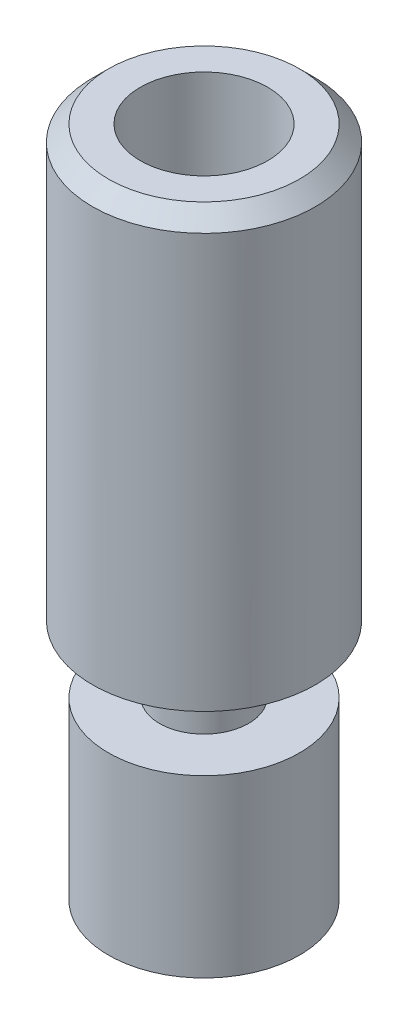
from build123d import *

# Parameters (mm, degrees)
CHAMFER1_SIZE = 0.5


with BuildPart() as part:
    # Sketch1 → Revolve1 (revolve)
    with BuildSketch(Plane.XY):
        Polygon((1, -10.55), (3, -10.55), (3, -5.05), (1.4, -5.05), (1.4, -2.95), (3.5, -2.95), (3.5, 10.55), (2, 10.55), (2, 6.55), (1, 5.972649731), align=None)
    revolve(axis=Axis((0, -10.55, 0), (0, 1, 0)))

    # Chamfer1
    chamfer1_edges = [part.edges().sort_by_distance(p)[0] for p in [
        (-3.5, 10.55, 0),
    ]]
    chamfer(chamfer1_edges, length=CHAMFER1_SIZE)


solid = part.part
